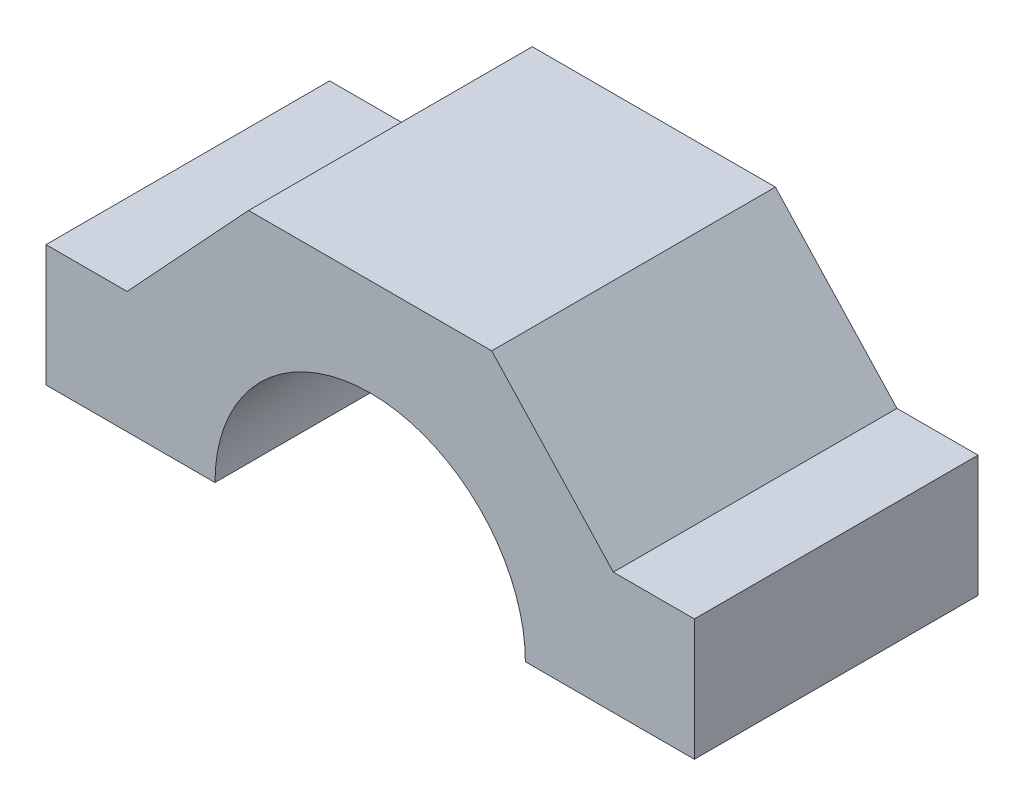
from build123d import *

# Parameters (mm, degrees)
BOSS_EXTRUDE3_DEPTH = 35
BOSS_EXTRUDE4_DEPTH = 3
SKETCH4_R           = 1.5
CUT_EXTRUDE2_DEPTH  = 4


with BuildPart() as part:
    # Sketch1 → Boss-Extrude3 (new body)
    with BuildSketch(Plane.XY):
        with BuildLine():
            Line((19.15, 0), (40, 0))
            Line((40, 0), (40, 15))
            Line((40, 15), (30, 15))
            Line((30, 15), (15, 31.15))
            Line((15, 31.15), (-15, 31.15))
            Line((-15, 31.15), (-30, 15))
            Line((-30, 15), (-40, 15))
            Line((-40, 15), (-40, 0))
            Line((-40, 0), (-19.15, 0))
            ThreePointArc((-19.15, 0), (0, 19.15), (19.15, 0))
        make_face()
    extrude(amount=BOSS_EXTRUDE3_DEPTH)

    # Sketch6 → Boss-Extrude4 (add)
    with BuildSketch(Plane(origin=(0, 0, 0), x_dir=(-1, 0, 0), z_dir=(0, 0, -1))):
        with BuildLine():
            Line((-19.15, 0), (-7.5, 0))
            ThreePointArc((-7.5, 0), (0, 7.5), (7.5, 0))
            Line((7.5, 0), (19.15, 0))
            ThreePointArc((19.15, 0), (0, 19.15), (-19.15, 0))
        make_face()
    extrude(amount=-BOSS_EXTRUDE4_DEPTH)

    # Sketch4 → Cut-Extrude2 (cut, through all)
    with BuildSketch(Plane.XY.offset(3)):
        with Locations((9.192388155, 9.192388155)):
            Circle(SKETCH4_R)
        with Locations((-9.192388155, 9.192388155)):
            Circle(SKETCH4_R)
    extrude(amount=-CUT_EXTRUDE2_DEPTH, mode=Mode.SUBTRACT)


solid = part.part
